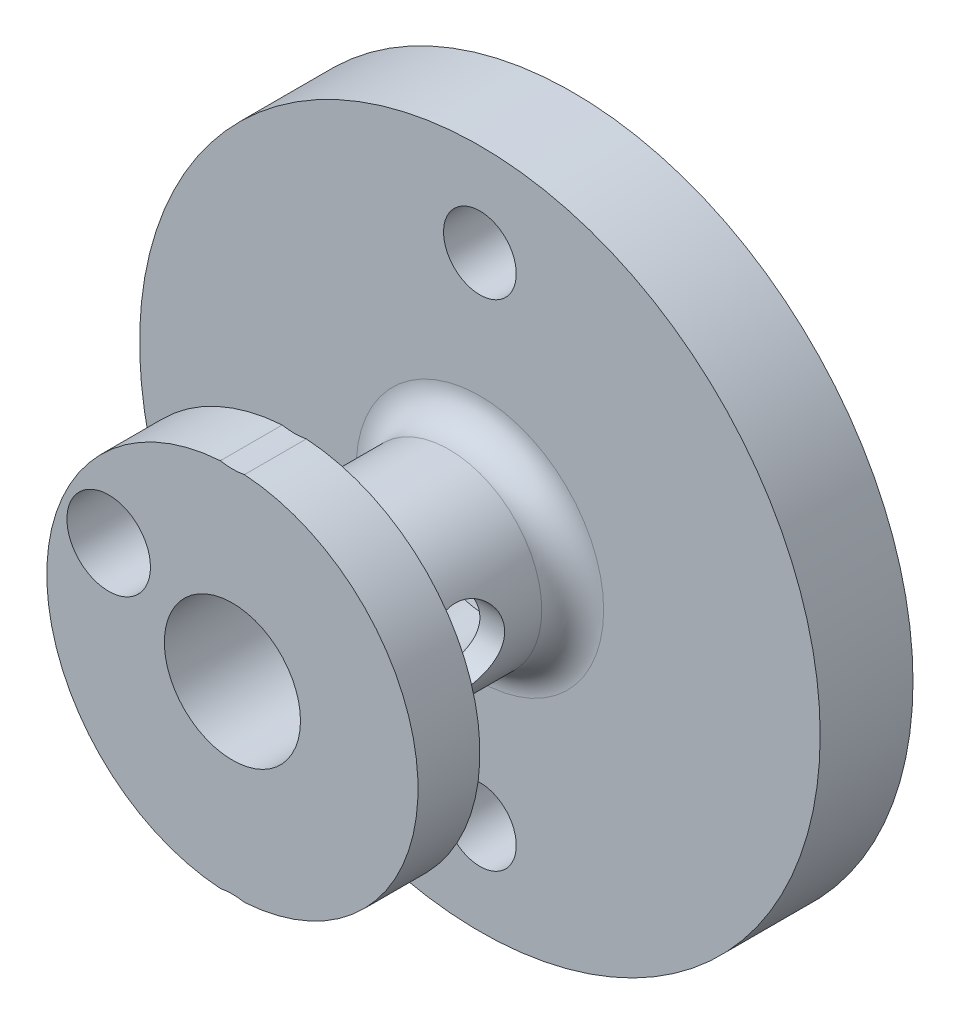
from build123d import *

# Parameters (mm, degrees)
SKETCH1_R                = 11
SKETCH1_R_2              = 4.175
MAIN_BODY_DEPTH          = 5.5
SKETCH2_R                = 4.175
SKETCH2_R_2              = 2.2
MAIN_BOLT_SURFACE_DEPTH  = 8.15
SKETCH7_R                = 1.175
CUT_EXTRUDE4_DEPTH       = 12
SKETCH8_R                = 2.05
CUT_EXTRUDE5_DEPTH       = 2
CUT_EXTRUDE9_START       = -2.5
SKETCH11_R               = 11
SKETCH11_R_2             = 3
CUT_EXTRUDE9_DEPTH       = 6
CUT_EXTRUDE10_REACH      = 13
SKETCH10_R               = 11
SKETCH10_R_2             = 6
FILLET2_R                = 1
SKETCH12_R               = 1.3
CUT_EXTRUDE12_DEPTH      = 12
CUT_EXTRUDE12_DEPTH_BACK = 12
SKETCH13_R               = 1.35
CUT_EXTRUDE13_DEPTH      = 5.5


with BuildPart() as part:
    # Sketch1 → Main Body (new body, symmetric)
    with BuildSketch(Plane.XY):
        Circle(SKETCH1_R)
        Circle(SKETCH1_R_2, mode=Mode.SUBTRACT)
    extrude(amount=MAIN_BODY_DEPTH, both=True)

    # Sketch2 → Main Bolt Surface (add)
    with BuildSketch(Plane.XY.offset(5.5)):
        Circle(SKETCH2_R)
        Circle(SKETCH2_R_2, mode=Mode.SUBTRACT)
    extrude(amount=-MAIN_BOLT_SURFACE_DEPTH)

    # Sketch7 → Cut-Extrude4 (cut, through all)
    with BuildSketch(Plane.XY.offset(5.5)):
        with Locations((0, -8)):
            Circle(SKETCH7_R)
        with Locations((0, 8)):
            Circle(SKETCH7_R)
    extrude(amount=-CUT_EXTRUDE4_DEPTH, mode=Mode.SUBTRACT)

    # Sketch8 → Cut-Extrude5 (cut)
    with BuildSketch(Plane.XY.offset(5.5)):
        with Locations((0, 8)):
            Circle(SKETCH8_R)
        with Locations((0, -8)):
            Circle(SKETCH8_R)
    extrude(amount=-CUT_EXTRUDE5_DEPTH, mode=Mode.SUBTRACT)

    # Sketch11 → Cut-Extrude9 (cut)
    with BuildSketch(Plane.XY.offset(CUT_EXTRUDE9_START)):
        Circle(SKETCH11_R)
        Circle(SKETCH11_R_2, mode=Mode.SUBTRACT)
    extrude(amount=CUT_EXTRUDE9_DEPTH, mode=Mode.SUBTRACT)

    # Sketch10 → Cut-Extrude10 (cut, up to next)
    with BuildSketch(Plane.XY.offset(5.5), mode=Mode.PRIVATE) as cut_extrude10_sk1:
        Circle(SKETCH10_R)
        Circle(SKETCH10_R_2, mode=Mode.SUBTRACT)
    cut_extrude10_tool1 = extrude(cut_extrude10_sk1.sketch, amount=-CUT_EXTRUDE10_REACH, mode=Mode.PRIVATE) & part.part
    add(cut_extrude10_tool1.solids().sort_by_distance((-10.688873, 0, 5.5))[0], mode=Mode.SUBTRACT)

    # Fillet2
    fillet2_edges = [part.edges().sort_by_distance(p)[0] for p in [
        (-3, 0, -2.5),
    ]]
    fillet(fillet2_edges, radius=FILLET2_R)

    # Sketch12 → Cut-Extrude12 (cut, two sides)
    with BuildSketch(Plane(origin=(0, 0, 0), x_dir=(0, 0, -1), z_dir=(1, 0, 0))) as cut_extrude12_sk:
        with Locations((-1, 0)):
            Circle(SKETCH12_R)
    extrude(amount=CUT_EXTRUDE12_DEPTH, mode=Mode.SUBTRACT)
    extrude(cut_extrude12_sk.sketch, amount=-CUT_EXTRUDE12_DEPTH_BACK, mode=Mode.SUBTRACT)

    # Sketch13 → Cut-Extrude13 (cut)
    with BuildSketch(Plane.XY.offset(5.5)):
        with Locations((-3.999386509, 1.877034489)):
            Circle(SKETCH13_R)
    extrude(amount=-CUT_EXTRUDE13_DEPTH, mode=Mode.SUBTRACT)


solid = part.part
